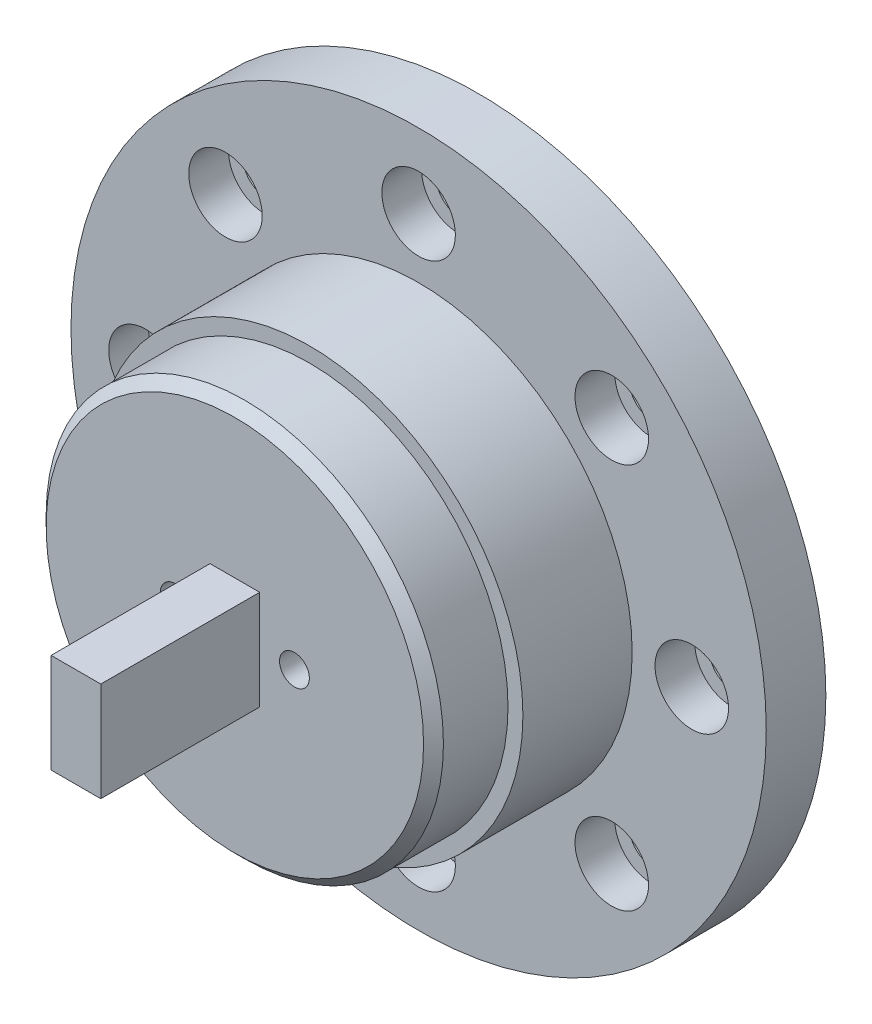
from build123d import *

# Parameters (mm, degrees)
SKETCH1_R           = 35
SKETCH1_R_2         = 2.2
BOSS_EXTRUDE1_DEPTH = 2
SKETCH2_R           = 35
SKETCH2_R_2         = 3.7
BOSS_EXTRUDE2_DEPTH = 4
SKETCH4_R           = 20
BOSS_EXTRUDE3_DEPTH = 18.5
SKETCH6_W           = 5
SKETCH6_H           = 10
BOSS_EXTRUDE4_DEPTH = 16
SKETCH7_R           = 21.5
BOSS_EXTRUDE5_DEPTH = 11
SKETCH5_R           = 1.5
CUT_EXTRUDE1_DEPTH  = 25.5
CHAMFER1_SIZE       = 1


with BuildPart() as part:
    # Sketch1 → Boss-Extrude1 (new body)
    with BuildSketch(Plane.XY):
        Circle(SKETCH1_R)
        with Locations((0, 27.5)):
            Circle(SKETCH1_R_2, mode=Mode.SUBTRACT)
        with Locations((19.445436483, 19.445436483)):
            Circle(SKETCH1_R_2, mode=Mode.SUBTRACT)
        with Locations((27.5, 0)):
            Circle(SKETCH1_R_2, mode=Mode.SUBTRACT)
        with Locations((19.445436483, -19.445436483)):
            Circle(SKETCH1_R_2, mode=Mode.SUBTRACT)
        with Locations((0, -27.5)):
            Circle(SKETCH1_R_2, mode=Mode.SUBTRACT)
        with Locations((-19.445436483, -19.445436483)):
            Circle(SKETCH1_R_2, mode=Mode.SUBTRACT)
        with Locations((-27.5, 0)):
            Circle(SKETCH1_R_2, mode=Mode.SUBTRACT)
        with Locations((-19.445436483, 19.445436483)):
            Circle(SKETCH1_R_2, mode=Mode.SUBTRACT)
    extrude(amount=BOSS_EXTRUDE1_DEPTH)

    # Sketch2 → Boss-Extrude2 (add)
    with BuildSketch(Plane.XY.offset(2)):
        Circle(SKETCH2_R)
        with Locations((-27.5, 0)):
            Circle(SKETCH2_R_2, mode=Mode.SUBTRACT)
        with Locations((0, -27.5)):
            Circle(SKETCH2_R_2, mode=Mode.SUBTRACT)
        with Locations((27.5, 0)):
            Circle(SKETCH2_R_2, mode=Mode.SUBTRACT)
        with Locations((0, 27.5)):
            Circle(SKETCH2_R_2, mode=Mode.SUBTRACT)
        with Locations((19.445436483, 19.445436483)):
            Circle(SKETCH2_R_2, mode=Mode.SUBTRACT)
        with Locations((19.445436483, -19.445436483)):
            Circle(SKETCH2_R_2, mode=Mode.SUBTRACT)
        with Locations((-19.445436483, -19.445436483)):
            Circle(SKETCH2_R_2, mode=Mode.SUBTRACT)
        with Locations((-19.445436483, 19.445436483)):
            Circle(SKETCH2_R_2, mode=Mode.SUBTRACT)
    extrude(amount=BOSS_EXTRUDE2_DEPTH)

    # Sketch4 → Boss-Extrude3 (add)
    with BuildSketch(Plane.XY.offset(6)):
        Circle(SKETCH4_R)
    extrude(amount=BOSS_EXTRUDE3_DEPTH)

    # Sketch6 → Boss-Extrude4 (add)
    with BuildSketch(Plane.XY.offset(24.5)):
        Rectangle(SKETCH6_W, SKETCH6_H)
    extrude(amount=BOSS_EXTRUDE4_DEPTH)

    # Sketch7 → Boss-Extrude5 (add)
    with BuildSketch(Plane.XY.offset(6)):
        Circle(SKETCH7_R)
    extrude(amount=BOSS_EXTRUDE5_DEPTH)

    # Sketch5 → Cut-Extrude1 (cut, through all)
    with BuildSketch(Plane.XY.offset(24.5)):
        with Locations((-6, 0)):
            Circle(SKETCH5_R)
        with Locations((6, 0)):
            Circle(SKETCH5_R)
    extrude(amount=-CUT_EXTRUDE1_DEPTH, mode=Mode.SUBTRACT)

    # Chamfer1
    chamfer1_edges = [part.edges().sort_by_distance(p)[0] for p in [
        (-20, 0, 24.5),
    ]]
    chamfer(chamfer1_edges, length=CHAMFER1_SIZE)


solid = part.part
